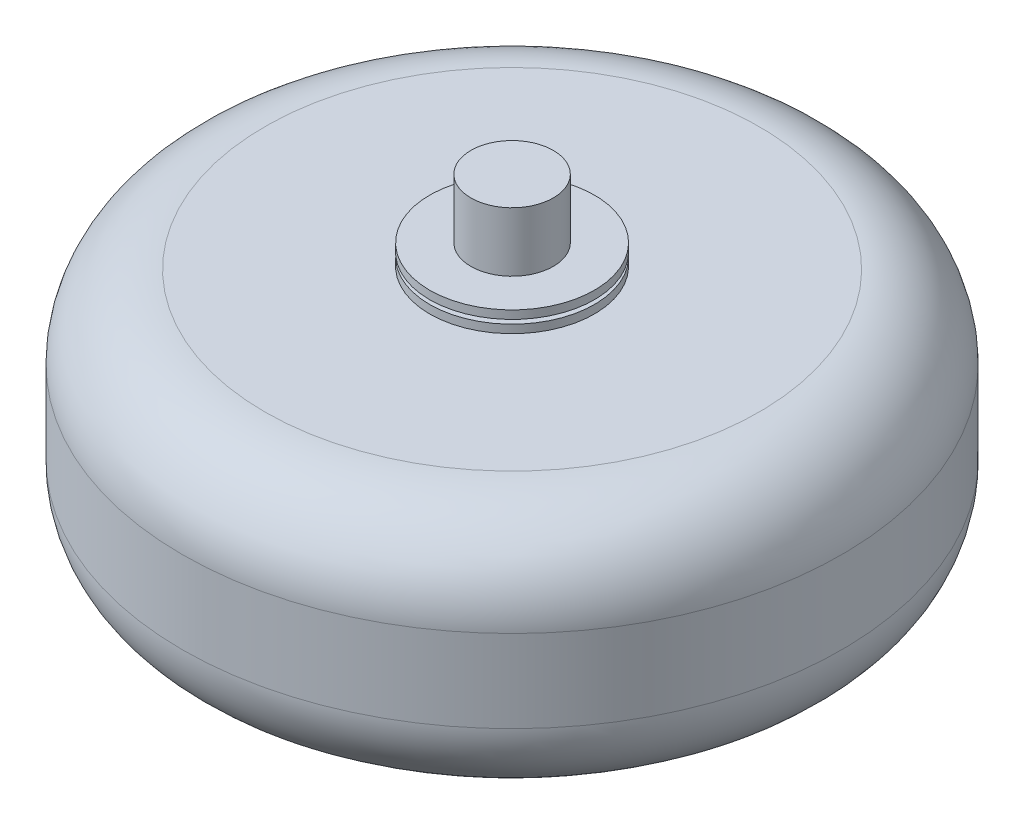
from build123d import *

# Parameters (mm, degrees)
BOSS_EXTRUDE1_DEPTH      = 38.1
BOSS_EXTRUDE1_DEPTH_BACK = 38.1
SKETCH1_R                = 101.6
SKETCH2_R                = 12.7
CUT_EXTRUDE1_DEPTH       = 76.2
FILLET1_R                = 25.4
BOSS_EXTRUDE2_DEPTH      = 63.5
BOSS_EXTRUDE2_DEPTH_BACK = 63.5
SKETCH3_R                = 12.7
SKETCH4_R                = 25.4
BOSS_EXTRUDE3_DEPTH      = 2.54
BOSS_EXTRUDE4_START      = -2.54
SKETCH5_R                = 25.4
BOSS_EXTRUDE4_DEPTH      = 2.54


with BuildPart() as part:
    # Sketch1 → Boss-Extrude1 (new, two sides: drawn at the far end of the back side and taken through both)
    with BuildSketch(Plane(origin=(0, 0, 0), x_dir=(1, 0, 0), z_dir=(0, 1, 0)).offset(-BOSS_EXTRUDE1_DEPTH_BACK)):
        Circle(SKETCH1_R)
    extrude(amount=BOSS_EXTRUDE1_DEPTH + BOSS_EXTRUDE1_DEPTH_BACK)

    # Sketch2 → Cut-Extrude1 (cut)
    with BuildSketch(Plane.XZ.offset(38.1)):
        Circle(SKETCH2_R)
    extrude(amount=-CUT_EXTRUDE1_DEPTH, mode=Mode.SUBTRACT)

    # Fillet1
    fillet1_edges = [part.edges().sort_by_distance(p)[0] for p in [
        (-101.6, 38.1, 0),
        (-101.6, -38.1, 0),
    ]]
    fillet(fillet1_edges, radius=FILLET1_R)

    # Sketch3 → Boss-Extrude2 (add, two sides: drawn at the far end of the back side and taken through both)
    with BuildSketch(Plane(origin=(0, 0, 0), x_dir=(1, 0, 0), z_dir=(0, 1, 0)).offset(-BOSS_EXTRUDE2_DEPTH_BACK)):
        Circle(SKETCH3_R)
    extrude(amount=BOSS_EXTRUDE2_DEPTH + BOSS_EXTRUDE2_DEPTH_BACK)

    # Sketch4 → Boss-Extrude3 (add)
    with BuildSketch(Plane(origin=(0, 42.672, 0), x_dir=(1, 0, 0), z_dir=(0, 1, 0))):
        Circle(SKETCH4_R)
    boss_extrude3 = extrude(amount=BOSS_EXTRUDE3_DEPTH)

    # Sketch5 → Boss-Extrude4 (add)
    with BuildSketch(Plane(origin=(0, 41.402, 0), x_dir=(1, 0, 0), z_dir=(0, 1, 0)).offset(BOSS_EXTRUDE4_START)):
        Circle(SKETCH5_R)
    boss_extrude4 = extrude(amount=BOSS_EXTRUDE4_DEPTH)

    # Mirror1: Boss-Extrude3, Boss-Extrude4 across plane
    add(boss_extrude3.mirror(Plane.ZX))
    add(boss_extrude4.mirror(Plane.ZX))


solid = part.part
